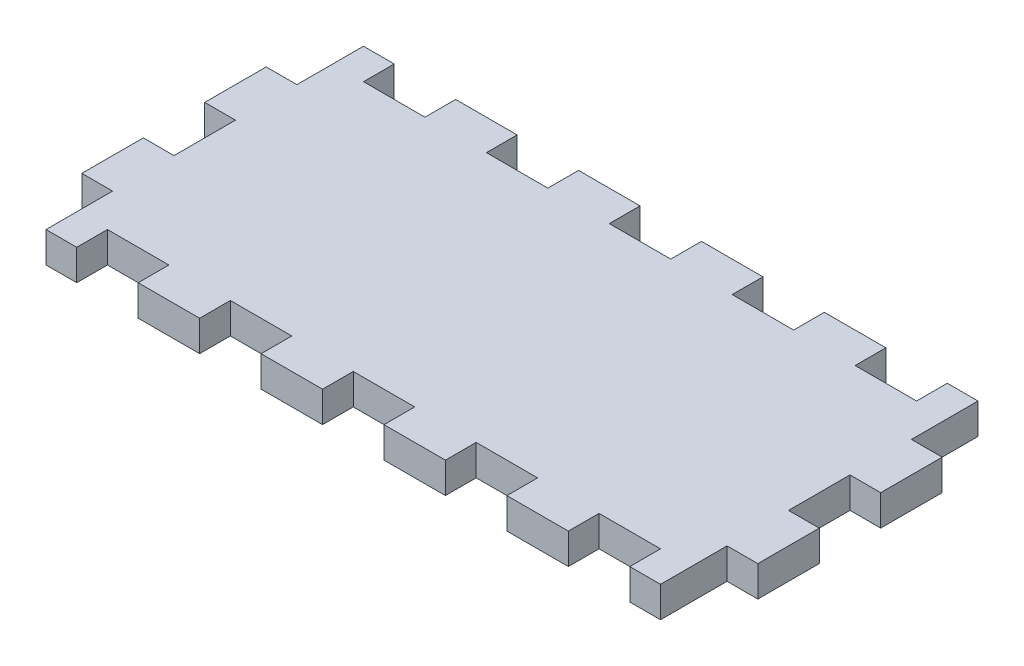
from build123d import *

# Parameters (mm, degrees)
BOSS_EXTRUDE1_DEPTH = 6


with BuildPart() as part:
    # Sketch1 → Boss-Extrude1 (new body)
    with BuildSketch(Plane(origin=(0, 0, 0), x_dir=(1, 0, 0), z_dir=(0, 1, 0))):
        Polygon((-60, -18), (-66, -18), (-66, -6), (-60, -6), (-60, 6), (-66, 6), (-66, 18), (-60, 18), (-60, 25), (-60, 31), (-54, 31), (-54, 25), (-42, 25), (-42, 31), (-30, 31), (-30, 25), (-18, 25), (-18, 31), (-6, 31), (-6, 25), (6, 25), (6, 31), (18, 31), (18, 25), (30, 25), (30, 31), (42, 31), (42, 25), (54, 25), (54, 31), (60, 31), (60, 25), (60, 18), (66, 18), (66, 6), (60, 6), (60, -6), (66, -6), (66, -18), (60, -18), (60, -25), (60, -31), (54, -31), (54, -25), (42, -25), (42, -31), (30, -31), (30, -25), (18, -25), (18, -31), (6, -31), (6, -25), (-6, -25), (-6, -31), (-18, -31), (-18, -25), (-30, -25), (-30, -31), (-42, -31), (-42, -25), (-54, -25), (-54, -31), (-60, -31), (-60, -25), align=None)
    extrude(amount=BOSS_EXTRUDE1_DEPTH)


solid = part.part
